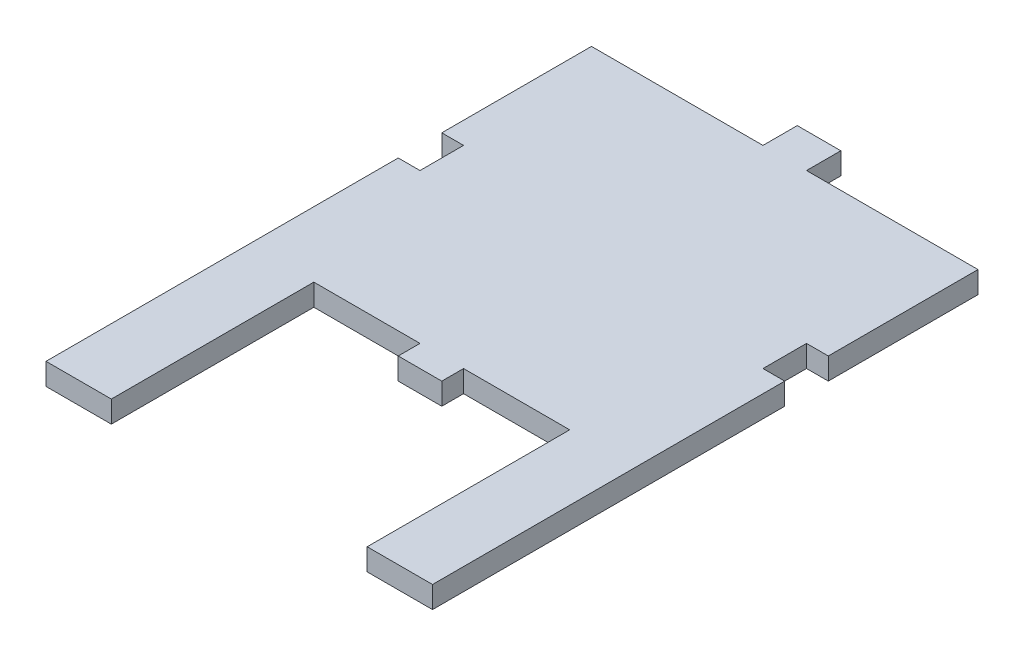
from build123d import *

# Parameters (mm, degrees)
SKETCH1_W           = 112.7
SKETCH1_H           = 100
BOSS_EXTRUDE1_DEPTH = 6.35
SKETCH2_W           = 6.35
SKETCH2_H           = 12.7
CUT_EXTRUDE1_DEPTH  = 76.601884897
CIRPATTERN1_COUNT   = 2
SKETCH5_W           = 12.7
SKETCH5_H           = 6.35
BOSS_EXTRUDE2_DEPTH = 6.35
SKETCH6_W           = 19.05
SKETCH6_H           = 6.35
BOSS_EXTRUDE3_DEPTH = 59.05
SKETCH7_W           = 12.7
SKETCH7_H           = 6.35
BOSS_EXTRUDE4_DEPTH = 10


with BuildPart() as part:
    # Sketch1 → Boss-Extrude1 (new body)
    with BuildSketch(Plane(origin=(0, 0, 0), x_dir=(1, 0, 0), z_dir=(0, 1, 0))):
        Rectangle(SKETCH1_W, SKETCH1_H)
    extrude(amount=BOSS_EXTRUDE1_DEPTH)

    # Sketch2 → Cut-Extrude1 (cut, through all)
    with BuildSketch(Plane(origin=(0, 6.35, 0), x_dir=(1, 0, 0), z_dir=(0, 1, 0))):
        with Locations((53.175, 0)):
            Rectangle(SKETCH2_W, SKETCH2_H)
    cut_extrude1 = extrude(amount=-CUT_EXTRUDE1_DEPTH, mode=Mode.SUBTRACT)

    # CirPattern1: Cut-Extrude1 ×2 about axis
    cirpattern1_axis = Axis((0, 6.35, 0), (0, 1, 0))
    for i in range(1, CIRPATTERN1_COUNT):
        add(cut_extrude1.rotate(cirpattern1_axis, i * 360 / CIRPATTERN1_COUNT), mode=Mode.SUBTRACT)

    # Sketch5 → Boss-Extrude2 (add)
    with BuildSketch(Plane.XY.offset(50)):
        with Locations((0, 3.175)):
            Rectangle(SKETCH5_W, SKETCH5_H)
    extrude(amount=BOSS_EXTRUDE2_DEPTH)

    # Sketch6 → Boss-Extrude3 (add)
    with BuildSketch(Plane.XY.offset(50)):
        with Locations((-46.825, 3.175)):
            Rectangle(SKETCH6_W, SKETCH6_H)
    boss_extrude3 = extrude(amount=BOSS_EXTRUDE3_DEPTH)

    # Mirror1: Boss-Extrude3 across plane
    add(boss_extrude3.mirror(Plane(origin=(0, 0, 0), x_dir=(0, 0, 1), z_dir=(1, 0, 0))))

    # Sketch7 → Boss-Extrude4 (add)
    with BuildSketch(Plane(origin=(0, 0, -50), x_dir=(-1, 0, 0), z_dir=(0, 0, -1))):
        with Locations((0, 3.175)):
            Rectangle(SKETCH7_W, SKETCH7_H)
    extrude(amount=BOSS_EXTRUDE4_DEPTH)


solid = part.part
